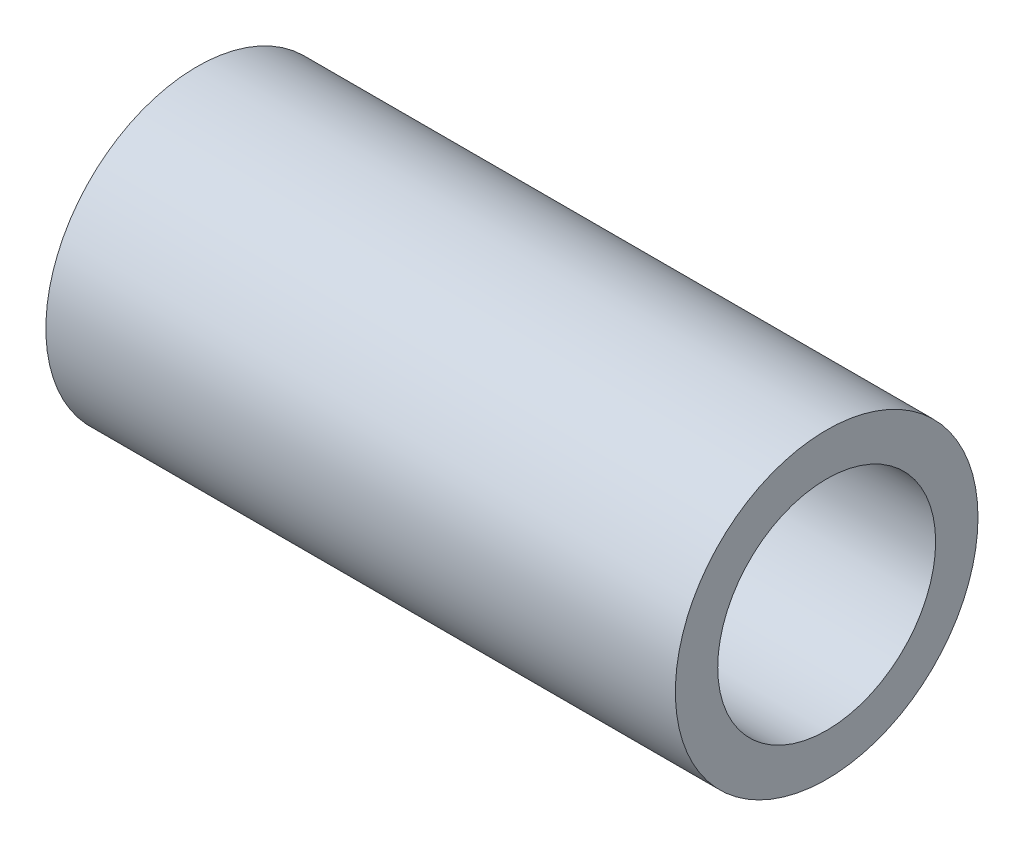
from build123d import *

# Parameters (mm, degrees)
SCHIZZO1_R                = 12.5
SCHIZZO1_R_2              = 9
ESTRUSIONE_SOTTILE1_DEPTH = 26


with BuildPart() as part:
    # Schizzo1 → Estrusione-Sottile1 (new body, symmetric)
    with BuildSketch(Plane(origin=(0, 0, 0), x_dir=(0, 0, -1), z_dir=(1, 0, 0))):
        Circle(SCHIZZO1_R)
        Circle(SCHIZZO1_R_2, mode=Mode.SUBTRACT)
    extrude(amount=ESTRUSIONE_SOTTILE1_DEPTH, both=True)


solid = part.part
